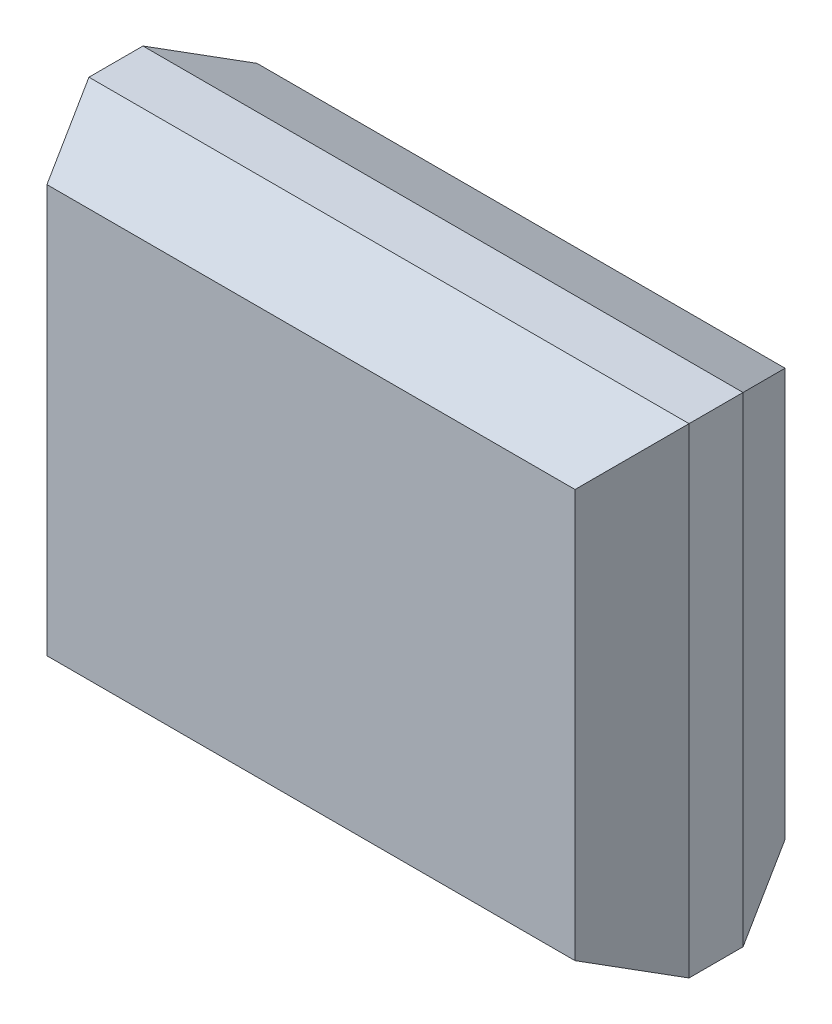
from build123d import *

# Parameters (mm, degrees)
ESQUISSE1_W        = 5
ESQUISSE1_H        = 4
BOSS_EXTRU_1_DEPTH = 1.75
CHANFREIN1_SIZE    = 0.65
CHANFREIN1_SIZE2   = 0.3
CHANFREIN2_SIZE    = 0.3
CHANFREIN2_SIZE2   = 0.65
CHANFREIN3_SIZE    = 0.65
CHANFREIN3_SIZE2   = 0.3
CHANFREIN4_SIZE    = 0.3
CHANFREIN4_SIZE2   = 0.65
CHANFREIN5_SIZE    = 0.65
CHANFREIN5_SIZE2   = 0.3
CHANFREIN6_SIZE    = 0.3
CHANFREIN6_SIZE2   = 0.65
CHANFREIN7_SIZE    = 0.65
CHANFREIN7_SIZE2   = 0.3
CHANFREIN8_SIZE    = 0.3
CHANFREIN8_SIZE2   = 0.65


with BuildPart() as part:
    # Esquisse1 → Boss.-Extru.1 (new body)
    with BuildSketch(Plane.XY):
        with Locations((2.5, 2)):
            Rectangle(ESQUISSE1_W, ESQUISSE1_H)
    extrude(amount=BOSS_EXTRU_1_DEPTH)

    # Chanfrein1
    chanfrein1_edges = [part.edges().sort_by_distance(p)[0] for p in [
        (2.5, 0, 1.75),
    ]]
    chanfrein1_side = [part.faces().sort_by_distance(p)[0] for p in [
        (2.5, 0, 0.875),
    ]]
    chamfer(chanfrein1_edges, length=CHANFREIN1_SIZE, length2=CHANFREIN1_SIZE2, reference=chanfrein1_side[0])

    # Chanfrein2
    chanfrein2_edges = [part.edges().sort_by_distance(p)[0] for p in [
        (2.5, 0, 0),
    ]]
    chanfrein2_side = [part.faces().sort_by_distance(p)[0] for p in [
        (2.5, 2, 0),
    ]]
    chamfer(chanfrein2_edges, length=CHANFREIN2_SIZE, length2=CHANFREIN2_SIZE2, reference=chanfrein2_side[0])

    # Chanfrein3
    chanfrein3_edges = [part.edges().sort_by_distance(p)[0] for p in [
        (2.5, 4, 1.75),
    ]]
    chanfrein3_side = [part.faces().sort_by_distance(p)[0] for p in [
        (2.5, 4, 0.875),
    ]]
    chamfer(chanfrein3_edges, length=CHANFREIN3_SIZE, length2=CHANFREIN3_SIZE2, reference=chanfrein3_side[0])

    # Chanfrein4
    chanfrein4_edges = [part.edges().sort_by_distance(p)[0] for p in [
        (2.5, 4, 0),
    ]]
    chanfrein4_side = [part.faces().sort_by_distance(p)[0] for p in [
        (2.5, 2.15, 0),
    ]]
    chamfer(chanfrein4_edges, length=CHANFREIN4_SIZE, length2=CHANFREIN4_SIZE2, reference=chanfrein4_side[0])

    # Chanfrein5
    chanfrein5_edges = [part.edges().sort_by_distance(p)[0] for p in [
        (0, 2, 1.75),
    ]]
    chanfrein5_side = [part.faces().sort_by_distance(p)[0] for p in [
        (0, 2, 0.875),
    ]]
    chamfer(chanfrein5_edges, length=CHANFREIN5_SIZE, length2=CHANFREIN5_SIZE2, reference=chanfrein5_side[0])

    # Chanfrein6
    chanfrein6_edges = [part.edges().sort_by_distance(p)[0] for p in [
        (0, 2, 0),
    ]]
    chanfrein6_side = [part.faces().sort_by_distance(p)[0] for p in [
        (2.5, 2, 0),
    ]]
    chamfer(chanfrein6_edges, length=CHANFREIN6_SIZE, length2=CHANFREIN6_SIZE2, reference=chanfrein6_side[0])

    # Chanfrein7
    chanfrein7_edges = [part.edges().sort_by_distance(p)[0] for p in [
        (5, 2, 1.75),
    ]]
    chanfrein7_side = [part.faces().sort_by_distance(p)[0] for p in [
        (5, 2, 0.875),
    ]]
    chamfer(chanfrein7_edges, length=CHANFREIN7_SIZE, length2=CHANFREIN7_SIZE2, reference=chanfrein7_side[0])

    # Chanfrein8
    chanfrein8_edges = [part.edges().sort_by_distance(p)[0] for p in [
        (5, 2, 0),
    ]]
    chanfrein8_side = [part.faces().sort_by_distance(p)[0] for p in [
        (2.65, 2, 0),
    ]]
    chamfer(chanfrein8_edges, length=CHANFREIN8_SIZE, length2=CHANFREIN8_SIZE2, reference=chanfrein8_side[0])


solid = part.part
